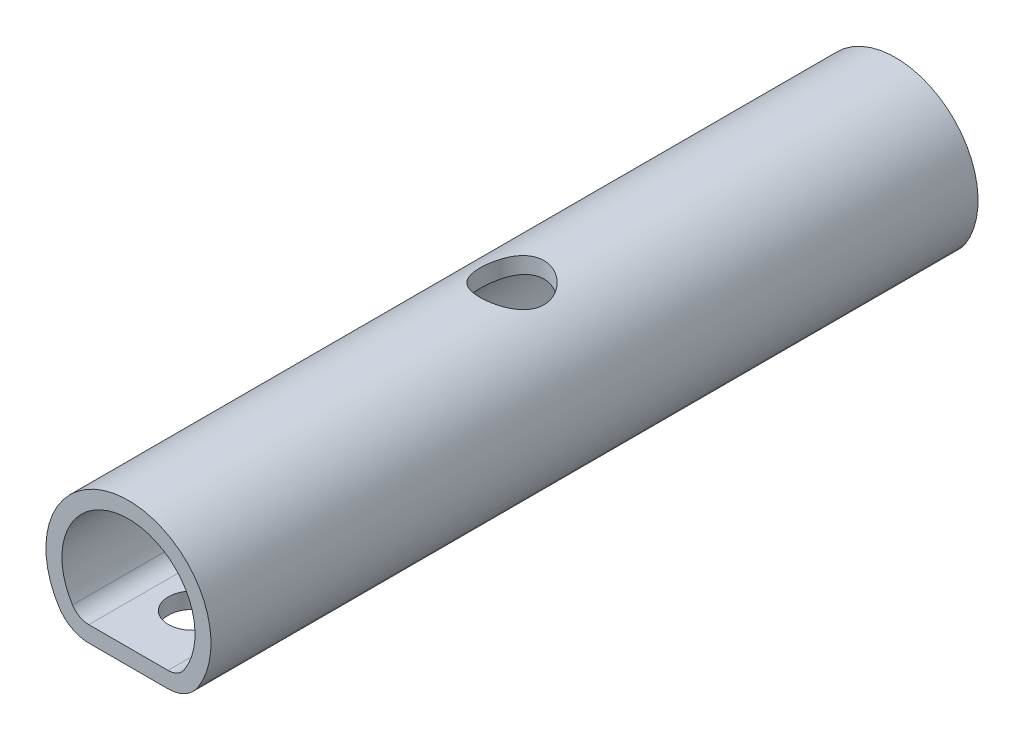
from build123d import *

# Parameters (mm, degrees)
BOSS_EXTRUDE1_DEPTH      = 76.2
CUT_EXTRUDE1_DEPTH       = 77.2
M4_CLEARANCE_HOLE1_D     = 4.7752
M4_CLEARANCE_HOLE1_DEPTH = 1.5875
HOLE1_D                  = 6.35
HOLE1_DEPTH              = 14.2494
FILLET1_R                = 1.9304
FILLET2_R                = 3.5179


with BuildPart() as part:
    # Sketch1 → Boss-Extrude1 (new body)
    with BuildSketch(Plane(origin=(0, 0, -38.1), x_dir=(-1, 0, 0), z_dir=(0, 0, -1))):
        with BuildLine():
            Line((-5.533344062, 4.9784), (5.533344062, 4.9784))
            ThreePointArc((5.533344062, 4.9784), (0, 19.2278), (-5.533344062, 4.9784))
        make_face()
    extrude(amount=-BOSS_EXTRUDE1_DEPTH)

    # Sketch2 → Cut-Extrude1 (cut, through all)
    with BuildSketch(Plane.XY.offset(38.1)):
        with BuildLine():
            Line((-4.878086413, 6.5659), (4.878086413, 6.5659))
            ThreePointArc((4.878086413, 6.5659), (0, 17.6403), (-4.878086413, 6.5659))
        make_face()
    extrude(amount=-CUT_EXTRUDE1_DEPTH, mode=Mode.SUBTRACT)

    # M4 Clearance Hole1
    with Locations(Plane(origin=(0, 4.9784, 0), x_dir=(-1, 0, 0), z_dir=(0, -1, 0))):
        with Locations((0, 0), (0, 31.75), (0, -31.75)):
            Hole(M4_CLEARANCE_HOLE1_D / 2, depth=M4_CLEARANCE_HOLE1_DEPTH)

    # Hole1
    with Locations(Plane(origin=(0, 19.2278, 0), x_dir=(1, 0, 0), z_dir=(0, 1, 0))):
        with Locations((0, 0)):
            Hole(HOLE1_D / 2, depth=HOLE1_DEPTH)

    # Fillet1
    fillet1_edges = [part.edges().sort_by_distance(p)[0] for p in [
        (-4.878086413, 6.5659, 0),
        (4.878086413, 6.5659, 0),
    ]]
    fillet(fillet1_edges, radius=FILLET1_R)

    # Fillet2
    fillet2_edges = [part.edges().sort_by_distance(p)[0] for p in [
        (-5.533344062, 4.9784, 0),
        (5.533344062, 4.9784, 0),
    ]]
    fillet(fillet2_edges, radius=FILLET2_R)


solid = part.part
